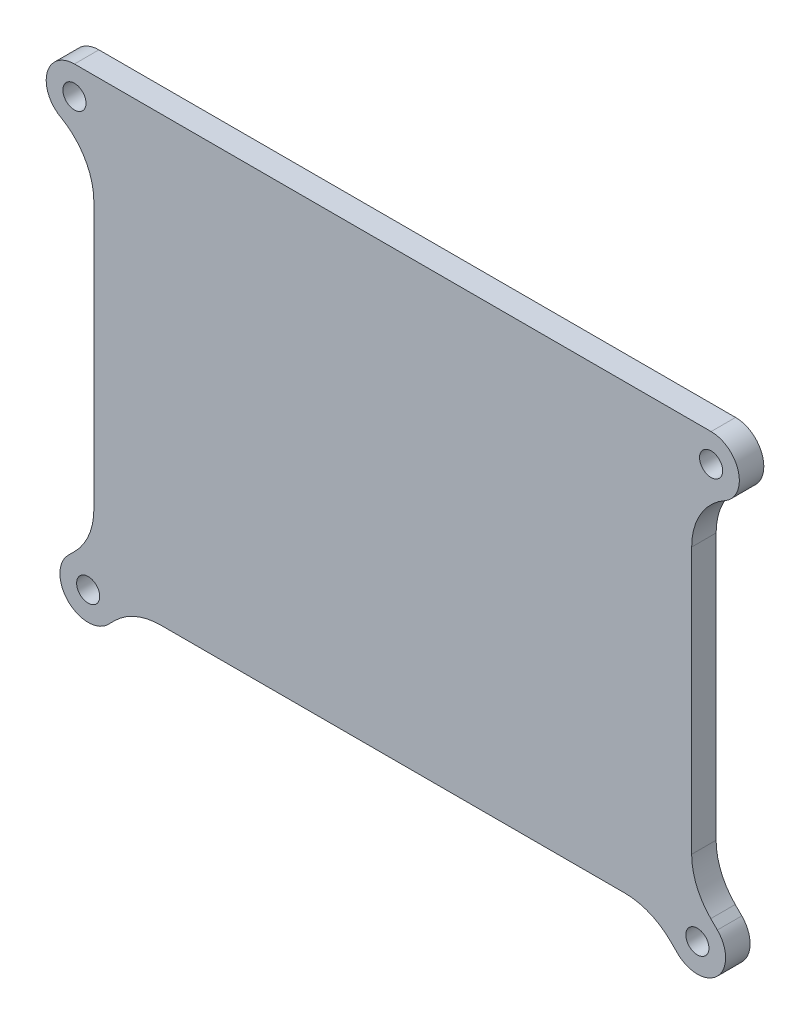
from build123d import *

# Parameters (mm, degrees)
BOSS_EXTRUDE1_DEPTH  = 4.7625
M4_CLEARANCE_HOLE1_D = 4.5


with BuildPart() as part:
    # Sketch2 → Boss-Extrude1 (new body)
    with BuildSketch(Plane.XY):
        with BuildLine():
            Line((-58.18125, 21.734258268), (-58.18125, -30.061313165))
            ThreePointArc((-58.18125, -30.061313165), (-59.147979937, -34.921392756), (-61.900993879, -39.041569286))
            Line((-61.900993879, -39.041569286), (-63.182817689, -40.323393096))
            ThreePointArc((-63.182817689, -40.323393096), (-63.182817689, -48.101567689), (-55.404643096, -48.101567689))
            Line((-55.404643096, -48.101567689), (-54.122819286, -46.819743879))
            ThreePointArc((-54.122819286, -46.819743879), (-50.002642756, -44.066729937), (-45.142563165, -43.1))
            Line((-45.142563165, -43.1), (45.142563165, -43.1))
            ThreePointArc((45.142563165, -43.1), (50.002642756, -44.066729937), (54.122819286, -46.819743879))
            Line((54.122819286, -46.819743879), (55.404643096, -48.101567689))
            ThreePointArc((55.404643096, -48.101567689), (63.182817689, -48.101567689), (63.182817689, -40.323393096))
            Line((63.182817689, -40.323393096), (61.900993879, -39.041569286))
            ThreePointArc((61.900993879, -39.041569286), (59.147979937, -34.921392756), (58.18125, -30.061313165))
            Line((58.18125, -30.061313165), (58.18125, 21.734258268))
            ThreePointArc((58.18125, 21.734258268), (59.919591901, 28.147685724), (64.658738462, 32.805407718))
            ThreePointArc((64.658738462, 32.805407718), (67.284676339, 38.9927926), (61.96395, 43.1))
            Line((61.96395, 43.1), (-61.96395, 43.1))
            ThreePointArc((-61.96395, 43.1), (-67.284676339, 38.9927926), (-64.658738462, 32.805407718))
            ThreePointArc((-64.658738462, 32.805407718), (-59.919591901, 28.147685724), (-58.18125, 21.734258268))
        make_face()
    extrude(amount=BOSS_EXTRUDE1_DEPTH)

    # M4 Clearance Hole1 (through all)
    with Locations(Plane.XY.offset(4.7625)):
        with Locations((-59.293730392, -44.212480392), (-61.96395, 37.6), (61.96395, 37.6), (59.293730392, -44.212480392)):
            Hole(M4_CLEARANCE_HOLE1_D / 2)


solid = part.part
